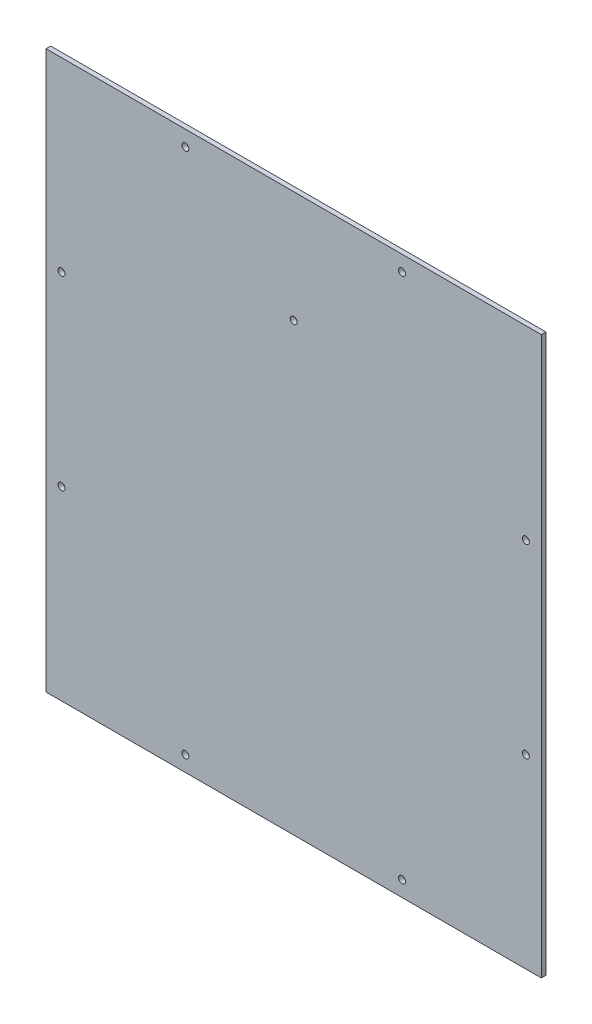
from build123d import *

# Parameters (mm, degrees)
SKETCH_1_W          = 320
SKETCH_1_H          = 360
SKETCH_1_R          = 2.25
EXTRUDE_1_DEPTH     = 3
SKETCH_2_R          = 2.25
CUT_EXTRUDE_1_DEPTH = 4


with BuildPart() as part:
    # Эскиз1 → Бобышка-Вытянуть1 (new body)
    with BuildSketch(Plane.XY):
        with Locations((160, 180)):
            Rectangle(SKETCH_1_W, SKETCH_1_H)
        with Locations((90, 350)):
            Circle(SKETCH_1_R, mode=Mode.SUBTRACT)
        with Locations((230, 350)):
            Circle(SKETCH_1_R, mode=Mode.SUBTRACT)
        with Locations((10, 240)):
            Circle(SKETCH_1_R, mode=Mode.SUBTRACT)
        with Locations((10, 120)):
            Circle(SKETCH_1_R, mode=Mode.SUBTRACT)
        with Locations((310, 240)):
            Circle(SKETCH_1_R, mode=Mode.SUBTRACT)
        with Locations((310, 120)):
            Circle(SKETCH_1_R, mode=Mode.SUBTRACT)
        with Locations((90, 10)):
            Circle(SKETCH_1_R, mode=Mode.SUBTRACT)
        with Locations((230, 10)):
            Circle(SKETCH_1_R, mode=Mode.SUBTRACT)
    extrude(amount=EXTRUDE_1_DEPTH)

    # Эскиз2 → Вырез-Вытянуть1 (cut, through all)
    with BuildSketch(Plane.XY.offset(3)):
        with Locations((160, 288)):
            Circle(SKETCH_2_R)
    extrude(amount=-CUT_EXTRUDE_1_DEPTH, mode=Mode.SUBTRACT)


solid = part.part
